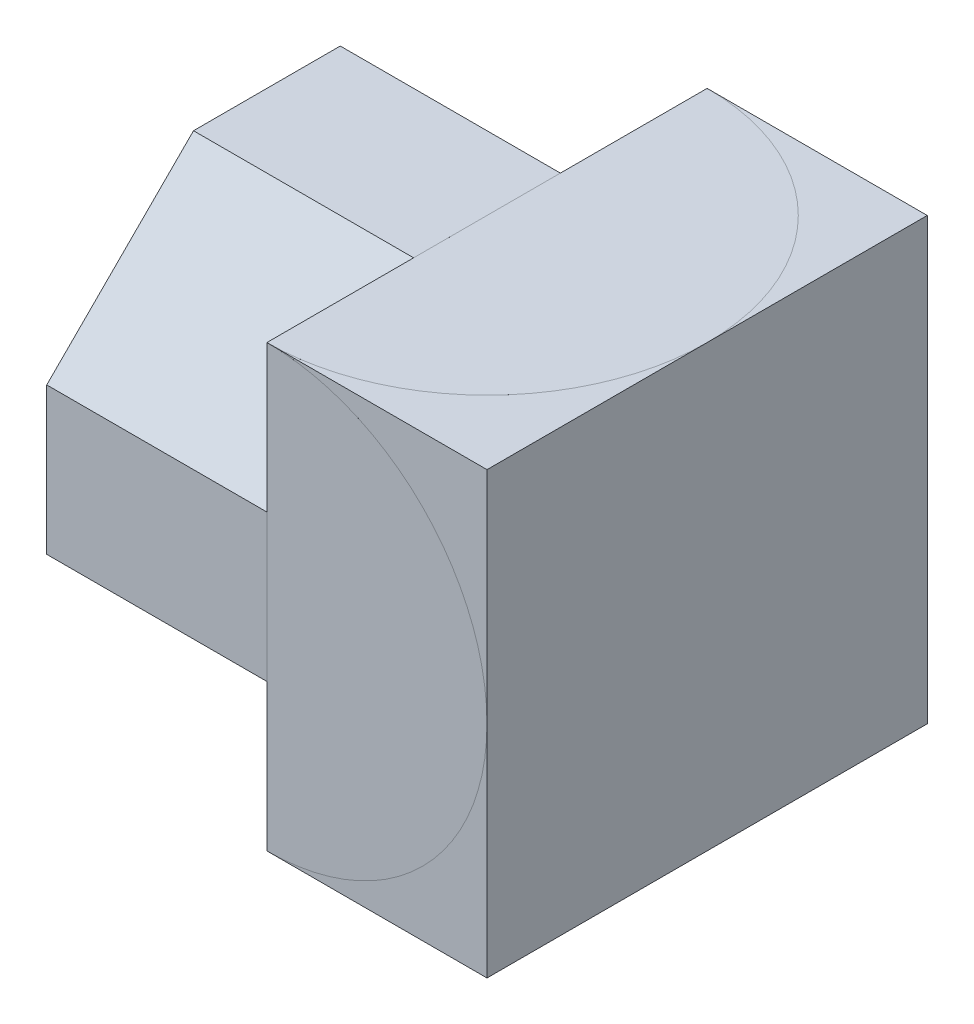
from build123d import *

# Parameters (mm, degrees)
SKETCH1_W           = 60
SKETCH1_H           = 60
BOSS_EXTRUDE1_DEPTH = 60
SKETCH3_W           = 30
SKETCH3_H           = 20
CUT_EXTRUDE1_DEPTH  = 20
SKETCH4_W           = 30
SKETCH4_H           = 20
CUT_EXTRUDE2_DEPTH  = 20
BOSS_EXTRUDE2_DEPTH = 30
CUT_EXTRUDE3_DEPTH  = 30
CUT_EXTRUDE4_DEPTH  = 30
CUT_EXTRUDE6_DEPTH  = 0.0001
CUT_EXTRUDE7_DEPTH  = 0.0001


with BuildPart() as part:
    # Sketch1 → Boss-Extrude1 (new body)
    with BuildSketch(Plane.XY):
        with Locations((30, 30)):
            Rectangle(SKETCH1_W, SKETCH1_H)
    extrude(amount=BOSS_EXTRUDE1_DEPTH)

    # Sketch3 → Cut-Extrude1 (cut)
    with BuildSketch(Plane(origin=(0, 60, 0), x_dir=(1, 0, 0), z_dir=(0, 1, 0))):
        with Locations((15, -10)):
            Rectangle(SKETCH3_W, SKETCH3_H)
    extrude(amount=-CUT_EXTRUDE1_DEPTH, mode=Mode.SUBTRACT)

    # Sketch4 → Cut-Extrude2 (cut)
    with BuildSketch(Plane(origin=(0, 60, 0), x_dir=(1, 0, 0), z_dir=(0, 1, 0))):
        with Locations((15, -50)):
            Rectangle(SKETCH4_W, SKETCH4_H)
    extrude(amount=-CUT_EXTRUDE2_DEPTH, mode=Mode.SUBTRACT)

    # Sketch5 → Boss-Extrude2 (add)
    with BuildSketch(Plane.ZY):
        Polygon((60, 40), (40, 60), (40, 40), align=None)
        Polygon((0, 40), (20, 40), (20, 60), align=None)
    extrude(amount=-BOSS_EXTRUDE2_DEPTH)

    # Sketch6 → Cut-Extrude3 (cut)
    with BuildSketch(Plane.ZY):
        Polygon((60, 20), (40, 0), (60, 0), align=None)
    extrude(amount=-CUT_EXTRUDE3_DEPTH, mode=Mode.SUBTRACT)

    # Sketch7 → Cut-Extrude4 (cut)
    with BuildSketch(Plane.ZY):
        Polygon((0, 20), (20, 0), (0, 0), align=None)
    extrude(amount=-CUT_EXTRUDE4_DEPTH, mode=Mode.SUBTRACT)

    # Sketch8 → Cut-Extrude6 (cut)
    with BuildSketch(Plane(origin=(0, 60, 0), x_dir=(1, 0, 0), z_dir=(0, 1, 0))):
        with BuildLine():
            Line((30, -60), (30, 0))
            ThreePointArc((30, 0), (60, -30), (30, -60))
        make_face()
    extrude(amount=-CUT_EXTRUDE6_DEPTH, mode=Mode.SUBTRACT)

    # Sketch9 → Cut-Extrude7 (cut)
    with BuildSketch(Plane.XY.offset(60)):
        with BuildLine():
            Line((30, 0), (30, 60))
            ThreePointArc((30, 60), (60, 30), (30, 0))
        make_face()
    extrude(amount=-CUT_EXTRUDE7_DEPTH, mode=Mode.SUBTRACT)


solid = part.part
